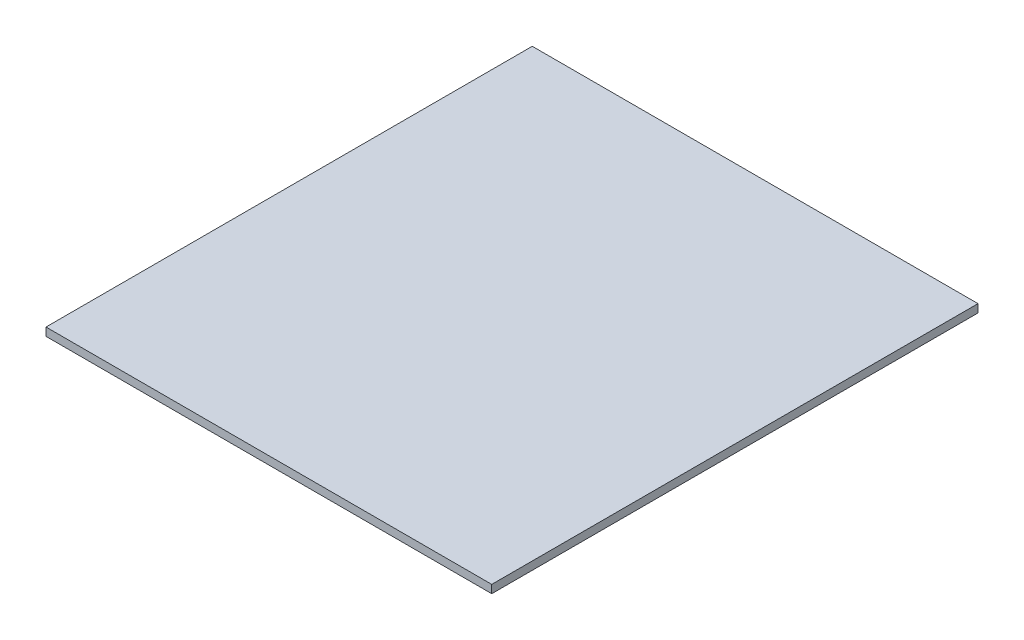
from build123d import *

# Parameters (mm, degrees)
SKETCH_1_W      = 110
SKETCH_1_H      = 120
EXTRUDE_1_DEPTH = 2


with BuildPart() as part:
    # 草图1 → 凸台-拉伸1 (new body)
    with BuildSketch(Plane(origin=(0, 0, 0), x_dir=(1, 0, 0), z_dir=(0, 1, 0))):
        Rectangle(SKETCH_1_W, SKETCH_1_H)
    extrude(amount=EXTRUDE_1_DEPTH)


solid = part.part
